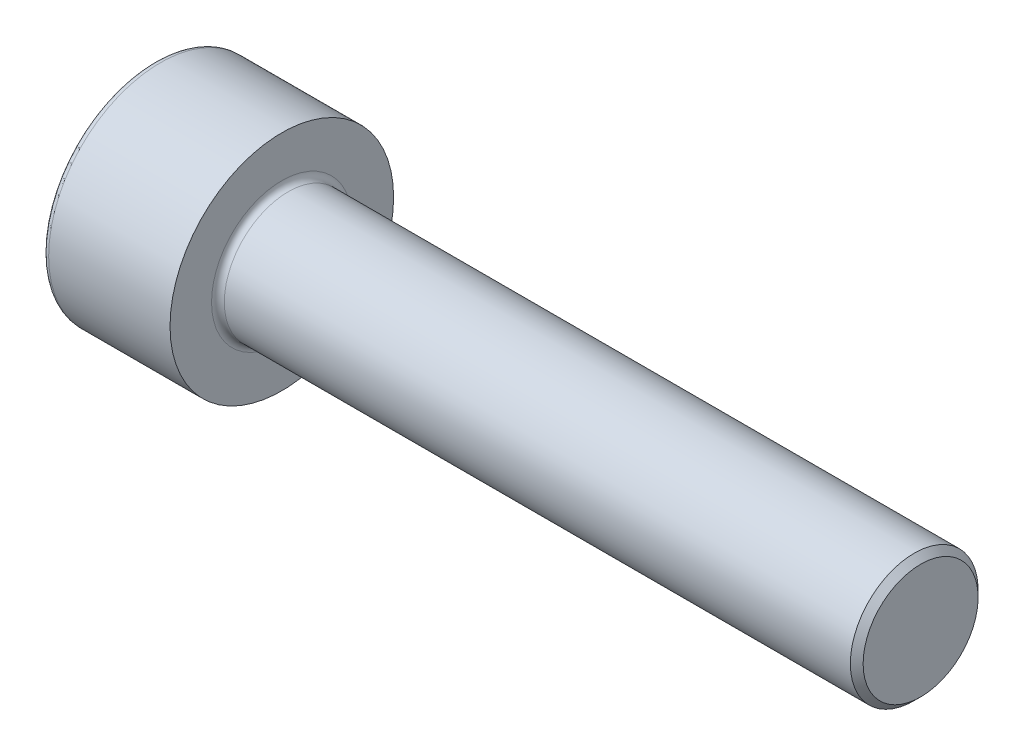
from build123d import *

# Parameters (mm, degrees)
HOLE_WIZARD_3_0_3_1_D     = 3
HOLE_WIZARD_3_0_3_1_DEPTH = 2.6
HOLE_WIZARD_3_0_3_1_TIP   = 0.901290929
CUT_EXTRUDE_1_DEPTH       = 2.6
FILLET_1_R                = 0.2
CHAMFER_1_SIZE            = 0.2


with BuildPart() as part:
    # 草图1 → 旋转1 (revolve)
    with BuildSketch(Plane.XY):
        Polygon((0, 0), (0, 3.5), (4, 3.5), (4, 2), (24, 2), (24, 0), align=None)
    revolve(axis=Axis((0, 0, 0), (1, 0, 0)))

    # Ø3.0 (3) 直径孔1
    with Locations(Plane.ZY):
        with Locations((0, 0)):
            Hole(HOLE_WIZARD_3_0_3_1_D / 2, depth=HOLE_WIZARD_3_0_3_1_DEPTH)
            with Locations((0, 0, -(HOLE_WIZARD_3_0_3_1_DEPTH + HOLE_WIZARD_3_0_3_1_TIP / 2))):  # 118° drill point
                Cone(0, HOLE_WIZARD_3_0_3_1_D / 2, HOLE_WIZARD_3_0_3_1_TIP, mode=Mode.SUBTRACT)

    # 草图2 → 切除-拉伸1 (cut)
    with BuildSketch(Plane.ZY):
        Polygon((0.866025404, 1.5), (-0.866025404, 1.5), (-1.732050808, 0), (-0.866025404, -1.5), (0.866025404, -1.5), (1.732050808, 0), align=None)
    extrude(amount=-CUT_EXTRUDE_1_DEPTH, mode=Mode.SUBTRACT)

    # 圆角1
    fillet_1_edges = [part.edges().sort_by_distance(p)[0] for p in [
        (4, -2, 0),
        (0, -3.5, 0),
    ]]
    fillet(fillet_1_edges, radius=FILLET_1_R)

    # 倒角1
    chamfer_1_edges = [part.edges().sort_by_distance(p)[0] for p in [
        (24, -2, 0),
    ]]
    chamfer(chamfer_1_edges, length=CHAMFER_1_SIZE)


solid = part.part
